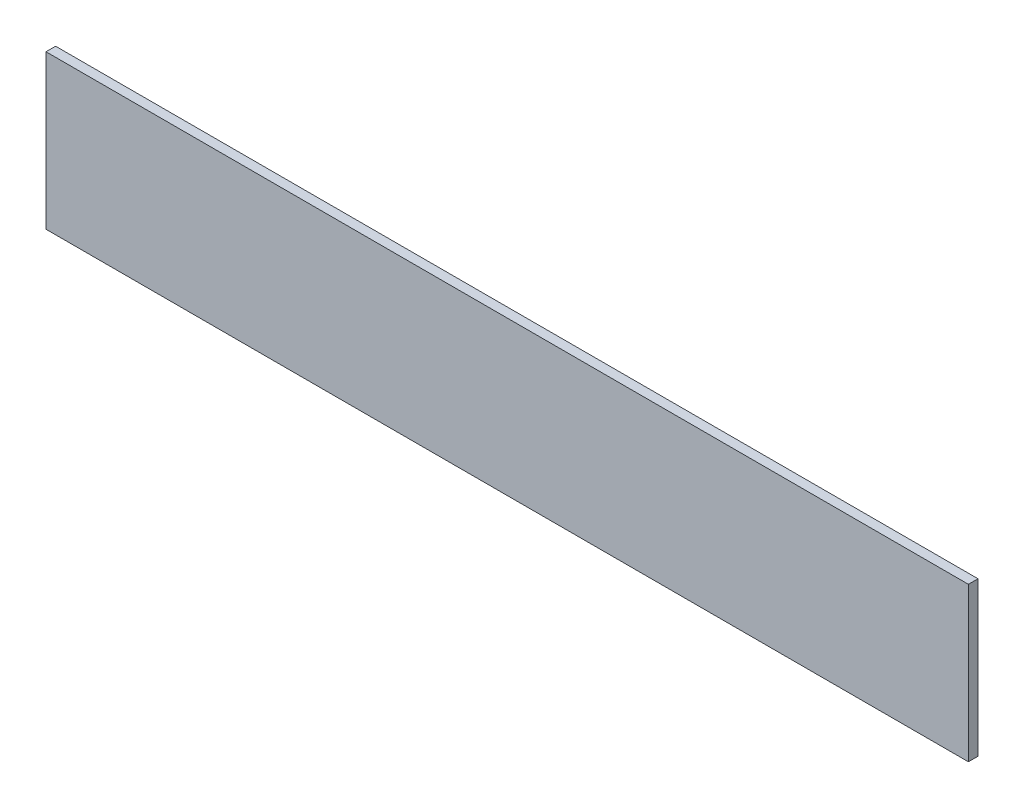
from build123d import *

# Parameters (mm, degrees)
SKETCH1_W           = 304.8
SKETCH1_H           = 50.8
BOSS_EXTRUDE1_DEPTH = 3.175


with BuildPart() as part:
    # Sketch1 → Boss-Extrude1 (new body)
    with BuildSketch(Plane.XY):
        Rectangle(SKETCH1_W, SKETCH1_H)
    extrude(amount=BOSS_EXTRUDE1_DEPTH)


solid = part.part
